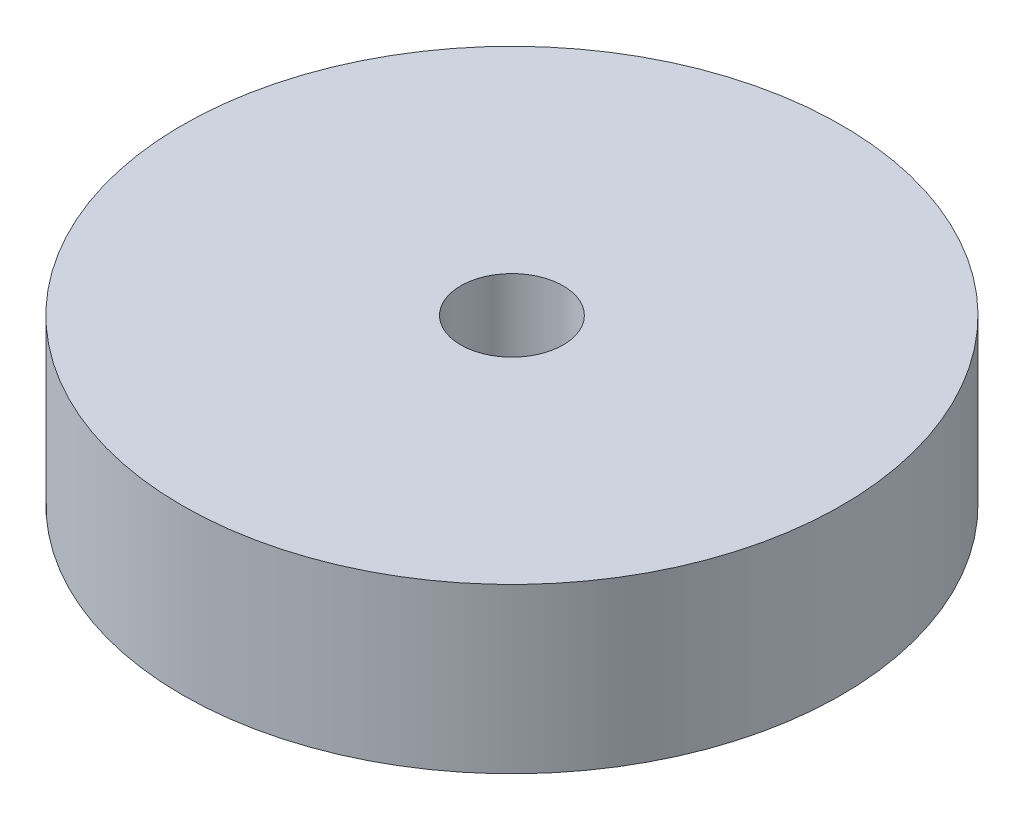
from build123d import *

# Parameters (mm, degrees)
SKETCH1_W = 8.6233
SKETCH1_H = 5.08


with BuildPart() as part:
    # Sketch1 → Revolve1 (revolve)
    with BuildSketch(Plane.XY):
        with Locations((-5.89915, -2.54)):
            Rectangle(SKETCH1_W, SKETCH1_H)
    revolve(axis=Axis((0, 0, 0), (0, -1, 0)))


solid = part.part
